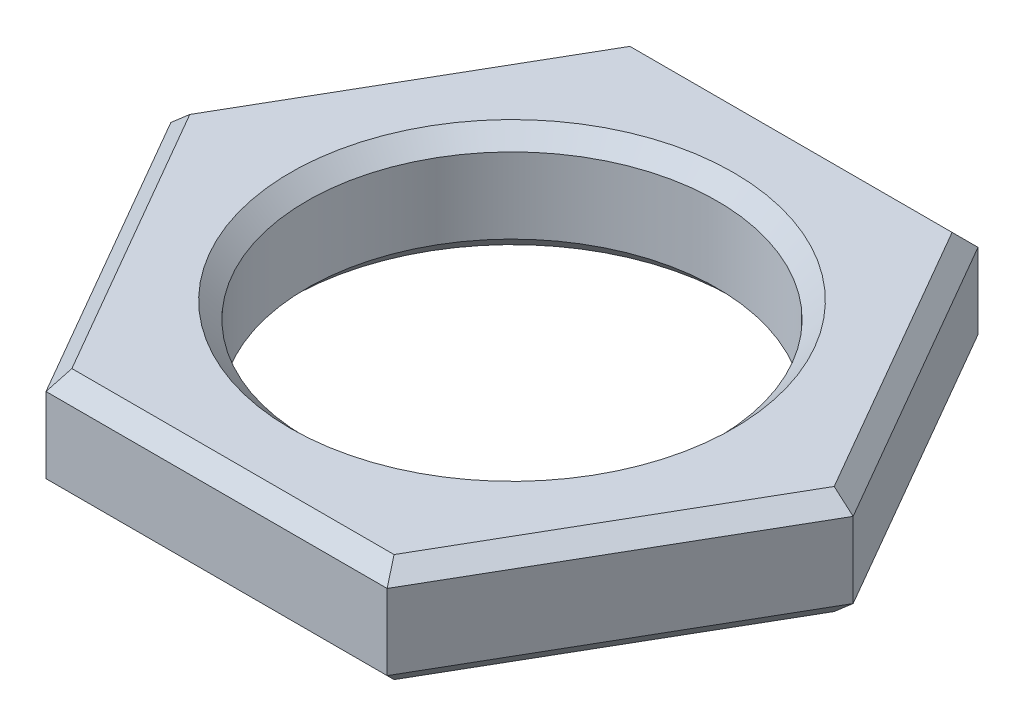
from build123d import *

# Parameters (mm, degrees)
SKETCH1_R           = 3.125
BOSS_EXTRUDE1_DEPTH = 1.65
CHAMFER1_SIZE       = 0.25


with BuildPart() as part:
    # Sketch1 → Boss-Extrude1 (new body)
    with BuildSketch(Plane(origin=(0, 0, 0), x_dir=(1, 0, 0), z_dir=(0, 1, 0))):
        Polygon((5.196152423, 0), (2.598076211, 4.5), (-2.598076211, 4.5), (-5.196152423, 0), (-2.598076211, -4.5), (2.598076211, -4.5), align=None)
        Circle(SKETCH1_R, mode=Mode.SUBTRACT)
    extrude(amount=BOSS_EXTRUDE1_DEPTH)

    # Chamfer1
    chamfer1_edges = [part.edges().sort_by_distance(p)[0] for p in [
        (0, 1.65, -4.5),
        (-3.897114317, 1.65, -2.25),
        (-3.897114317, 1.65, 2.25),
        (-3.125, 0, 0),
        (-3.125, 1.65, 0),
        (0, 1.65, 4.5),
        (3.897114317, 1.65, 2.25),
        (0, 0, 4.5),
        (-3.897114317, 0, 2.25),
        (-3.897114317, 0, -2.25),
        (3.897114317, 1.65, -2.25),
        (0, 0, -4.5),
        (3.897114317, 0, -2.25),
        (3.897114317, 0, 2.25),
    ]]
    chamfer(chamfer1_edges, length=CHAMFER1_SIZE)


solid = part.part
